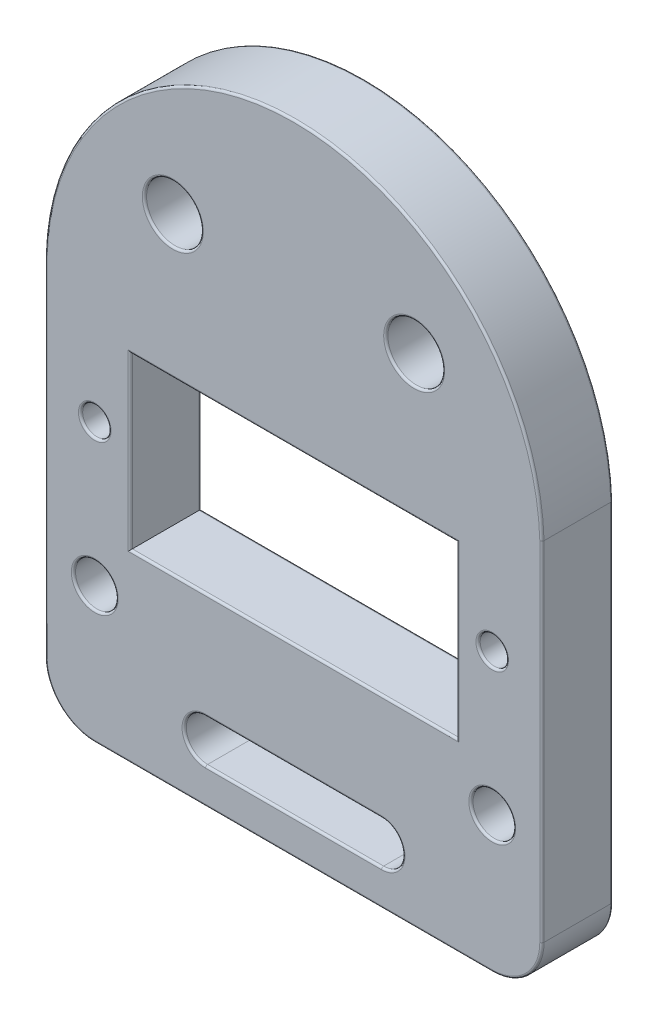
from build123d import *

# Parameters (mm, degrees)
SKETCH1_R           = 2
SKETCH1_R_2         = 1
SKETCH1_R_3         = 1.5
SKETCH1_W           = 23
SKETCH1_H           = 12
BOSS_EXTRUDE1_DEPTH = 5
FILLET1_R           = 3.5
FILLET2_R           = 0.15


with BuildPart() as part:
    # Sketch1 → Boss-Extrude1 (new body)
    with BuildSketch(Plane.XY):
        with BuildLine():
            Line((-17.5, 9), (-17.5, -19))
            Line((-17.5, -19), (17.5, -19))
            Line((17.5, -19), (17.5, 9))
            ThreePointArc((17.5, 9), (0, 26), (-17.5, 9))
        make_face()
        with Locations((-8.5, 16)):
            Circle(SKETCH1_R, mode=Mode.SUBTRACT)
        with Locations((-14, 0.587956268)):
            Circle(SKETCH1_R_2, mode=Mode.SUBTRACT)
        with Locations((-14, -9.412043732)):
            Circle(SKETCH1_R_3, mode=Mode.SUBTRACT)
        with Locations((8.5, 16)):
            Circle(SKETCH1_R, mode=Mode.SUBTRACT)
        with Locations((14, 0.587956268)):
            Circle(SKETCH1_R_2, mode=Mode.SUBTRACT)
        with Locations((14, -9.412043732)):
            Circle(SKETCH1_R_3, mode=Mode.SUBTRACT)
        Rectangle(SKETCH1_W, SKETCH1_H, mode=Mode.SUBTRACT)
        with BuildLine():
            Line((-6.2, -13.5), (6.2, -13.5))
            ThreePointArc((6.2, -13.5), (7.7, -15), (6.2, -16.5))
            Line((6.2, -16.5), (-6.2, -16.5))
            ThreePointArc((-6.2, -16.5), (-7.7, -15), (-6.2, -13.5))
        make_face(mode=Mode.SUBTRACT)
    extrude(amount=BOSS_EXTRUDE1_DEPTH)

    # Fillet1
    fillet1_edges = [part.edges().sort_by_distance(p)[0] for p in [
        (17.5, -19, 2.5),
        (-17.5, -19, 2.5),
    ]]
    fillet(fillet1_edges, radius=FILLET1_R)

    # Fillet2
    fillet2_edges = [part.edges().sort_by_distance(p)[0] for p in [
        (11.5, 0, 0),
        (0, 6, 0),
        (-11.5, 0, 0),
        (0, -6, 0),
        (11.5, 0, 5),
        (0, 6, 5),
        (-11.5, 0, 5),
        (0, -6, 5),
        (-10.5, 16, 0),
        (-10.5, 16, 5),
        (-15, 0.587956268, 0),
        (-15, 0.587956268, 5),
        (-15.5, -9.412043732, 0),
        (-15.5, -9.412043732, 5),
        (6.5, 16, 0),
        (6.5, 16, 5),
        (13, 0.587956268, 0),
        (13, 0.587956268, 5),
        (12.5, -9.412043732, 0),
        (12.5, -9.412043732, 5),
        (0, 26, 5),
        (-7.7, -15, 0),
        (0, -16.5, 0),
        (7.7, -15, 0),
        (0, -13.5, 0),
        (-7.7, -15, 5),
        (0, -16.5, 5),
        (7.7, -15, 5),
        (0, -13.5, 5),
        (-17.5, -3.25, 0),
        (0, 26, 0),
        (17.5, -3.25, 0),
        (17.5, -3.25, 5),
        (0, -19, 0),
        (-16.474873734, -17.974873734, 0),
        (16.474873734, -17.974873734, 0),
        (0, -19, 5),
        (-16.474873734, -17.974873734, 5),
        (16.474873734, -17.974873734, 5),
        (-17.5, -3.25, 5),
    ]]
    fillet(fillet2_edges, radius=FILLET2_R)


solid = part.part
